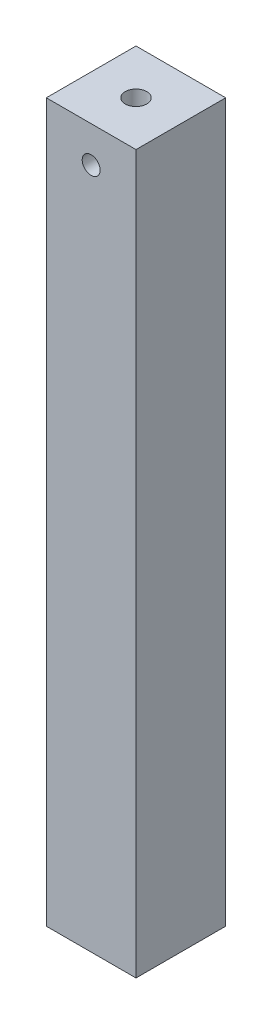
from build123d import *

# Parameters (mm, degrees)
SKETCH1_W           = 25
SKETCH1_H           = 25
SKETCH1_R           = 3
BOSS_EXTRUDE1_DEPTH = 200
SKETCH2_R           = 2.5
CUT_EXTRUDE1_DEPTH  = 26


with BuildPart() as part:
    # Sketch1 → Boss-Extrude1 (new body)
    with BuildSketch(Plane(origin=(0, 0, 0), x_dir=(1, 0, 0), z_dir=(0, 1, 0))):
        with Locations((-7.413793103, -2.327586207)):
            Rectangle(SKETCH1_W, SKETCH1_H)
        with Locations((-7.413793103, -2.327586207)):
            Circle(SKETCH1_R, mode=Mode.SUBTRACT)
    extrude(amount=BOSS_EXTRUDE1_DEPTH)

    # Sketch2 → Cut-Extrude1 (cut, through all)
    with BuildSketch(Plane.XY.offset(14.827586207)):
        with Locations((-7.413793103, 190)):
            Circle(SKETCH2_R)
    extrude(amount=-CUT_EXTRUDE1_DEPTH, mode=Mode.SUBTRACT)


solid = part.part
